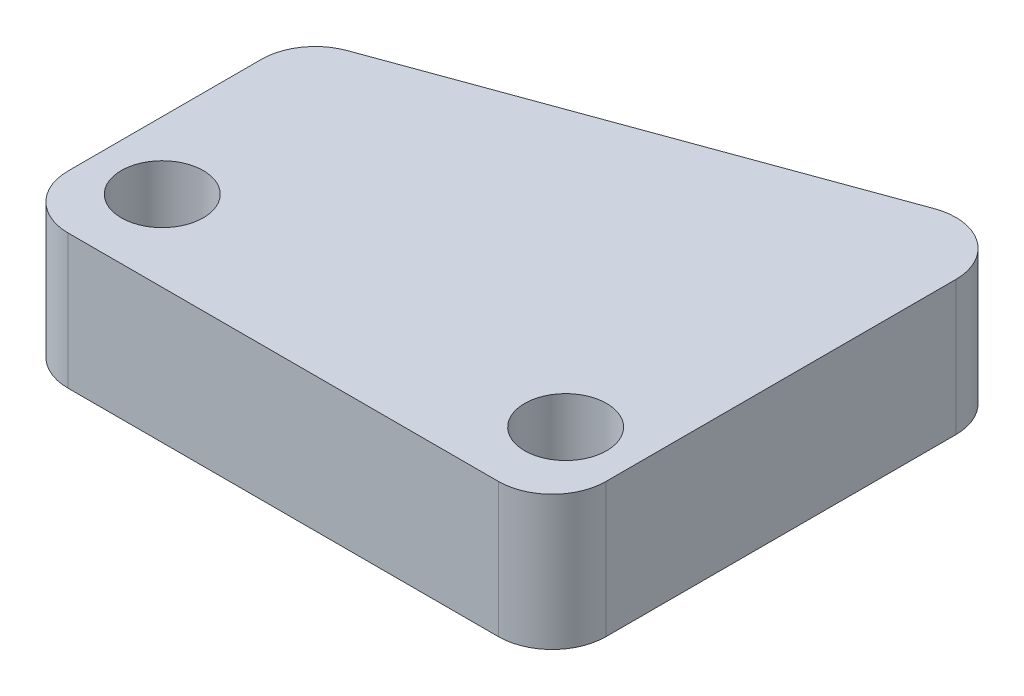
from build123d import *

# Parameters (mm, degrees)
SKETCH_1_W          = 20
SKETCH_1_H          = 20
EXTRUDE_1_DEPTH     = 5
SKETCH_2_R          = 1.525
CUT_EXTRUDE_1_DEPTH = 10
CUT_EXTRUDE_2_DEPTH = 6
FILLET_2_R          = 2


with BuildPart() as part:
    # 草图1 → 凸台-拉伸1 (new body)
    with BuildSketch(Plane(origin=(0, 0, 0), x_dir=(1, 0, 0), z_dir=(0, 1, 0))):
        Rectangle(SKETCH_1_W, SKETCH_1_H)
    extrude(amount=EXTRUDE_1_DEPTH)

    # 草图2 → 切除-拉伸1 (cut)
    with BuildSketch(Plane(origin=(0, 5, 0), x_dir=(1, 0, 0), z_dir=(0, 1, 0))):
        with Locations((-7.5, -7)):
            Circle(SKETCH_2_R)
        with Locations((7.5, -7)):
            Circle(SKETCH_2_R)
    extrude(amount=-CUT_EXTRUDE_1_DEPTH, mode=Mode.SUBTRACT)

    # 草图3 → 切除-拉伸2 (cut, through all)
    with BuildSketch(Plane(origin=(0, 5, 0), x_dir=(1, 0, 0), z_dir=(0, 1, 0))):
        Polygon((-10, 10), (-10, 0.585811222), (10, 7.865215908), (10, 10), align=None)
    extrude(amount=-CUT_EXTRUDE_2_DEPTH, mode=Mode.SUBTRACT)

    # 圆角2
    fillet_2_edges = [part.edges().sort_by_distance(p)[0] for p in [
        (-10, 2.5, -0.585811222),
        (10, 2.5, -7.865215908),
        (10, 2.5, 10),
        (-10, 2.5, 10),
    ]]
    fillet(fillet_2_edges, radius=FILLET_2_R)


solid = part.part
